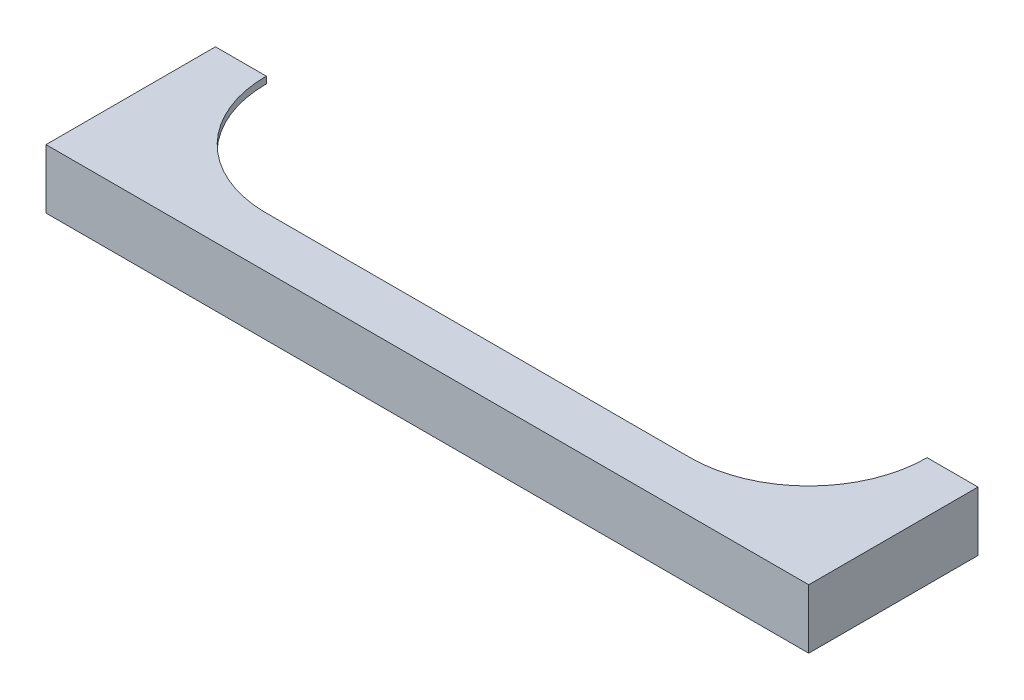
from build123d import *

# Parameters (mm, degrees)
BOSS_EXTRUDE1_DEPTH = 700
SKETCH6_W           = 8920
SKETCH6_H           = 620
CUT_EXTRUDE1_DEPTH  = 2400


with BuildPart() as part:
    # Sketch1 → Boss-Extrude1 (new body)
    with BuildSketch(Plane(origin=(0, 0, 0), x_dir=(1, 0, 0), z_dir=(0, 1, 0))):
        with BuildLine():
            Line((-4500, 0), (4499.999692814, 2.35145561))
            Line((4499.999692814, 2.35145561), (4500, 2000))
            Line((4500, 2000), (3900, 2000))
            ThreePointArc((3900, 2000), (3490.485314986, 1011.344093449), (2501.829408435, 601.829408435))
            Line((2501.829408435, 601.829408435), (-2537.88413688, 600.512668091))
            ThreePointArc((-2537.88413688, 600.512668091), (-3503.254153152, 1023.536429669), (-3900, 2000))
            Line((-3900, 2000), (-4500, 2000))
            Line((-4500, 2000), (-4500, 0))
        make_face()
    extrude(amount=BOSS_EXTRUDE1_DEPTH)

    # Sketch6 → Cut-Extrude1 (cut)
    with BuildSketch(Plane.XY.offset(-2500)):
        with Locations((0, 310)):
            Rectangle(SKETCH6_W, SKETCH6_H)
    extrude(amount=CUT_EXTRUDE1_DEPTH, mode=Mode.SUBTRACT)


solid = part.part
